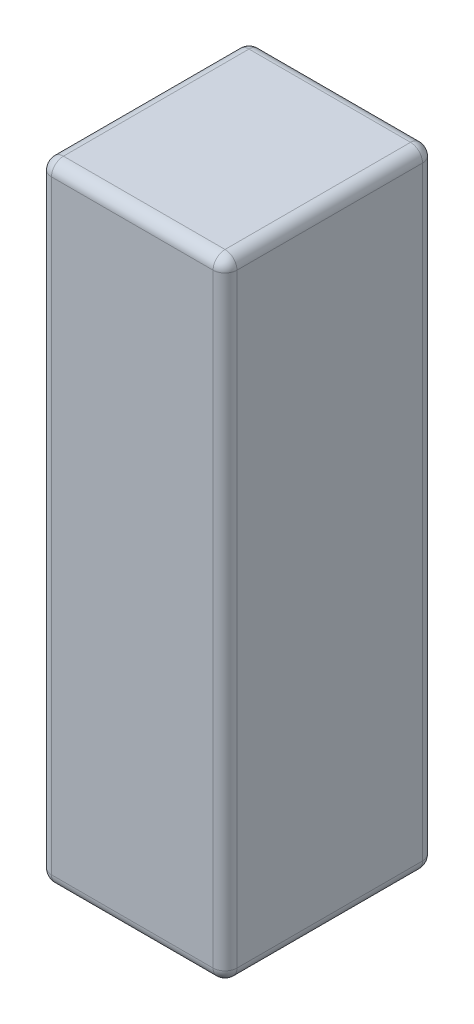
from build123d import *

# Parameters (mm, degrees)
SKETCH1_W           = 31
SKETCH1_H           = 35
BOSS_EXTRUDE1_DEPTH = 105
FILLET1_R           = 2


with BuildPart() as part:
    # Sketch1 → Boss-Extrude1 (new body)
    with BuildSketch(Plane(origin=(0, 0, 0), x_dir=(1, 0, 0), z_dir=(0, 1, 0))):
        with Locations((15.5, 17.5)):
            Rectangle(SKETCH1_W, SKETCH1_H)
    extrude(amount=BOSS_EXTRUDE1_DEPTH)

    # Fillet1
    fillet1_edges = [part.edges().sort_by_distance(p)[0] for p in [
        (31, 105, -17.5),
        (15.5, 105, -35),
        (0, 105, -17.5),
        (15.5, 0, -35),
        (31, 0, -17.5),
        (15.5, 0, 0),
        (0, 0, -17.5),
        (15.5, 105, 0),
        (0, 52.5, -35),
        (31, 52.5, -35),
        (31, 52.5, 0),
        (0, 52.5, 0),
    ]]
    fillet(fillet1_edges, radius=FILLET1_R)


solid = part.part
